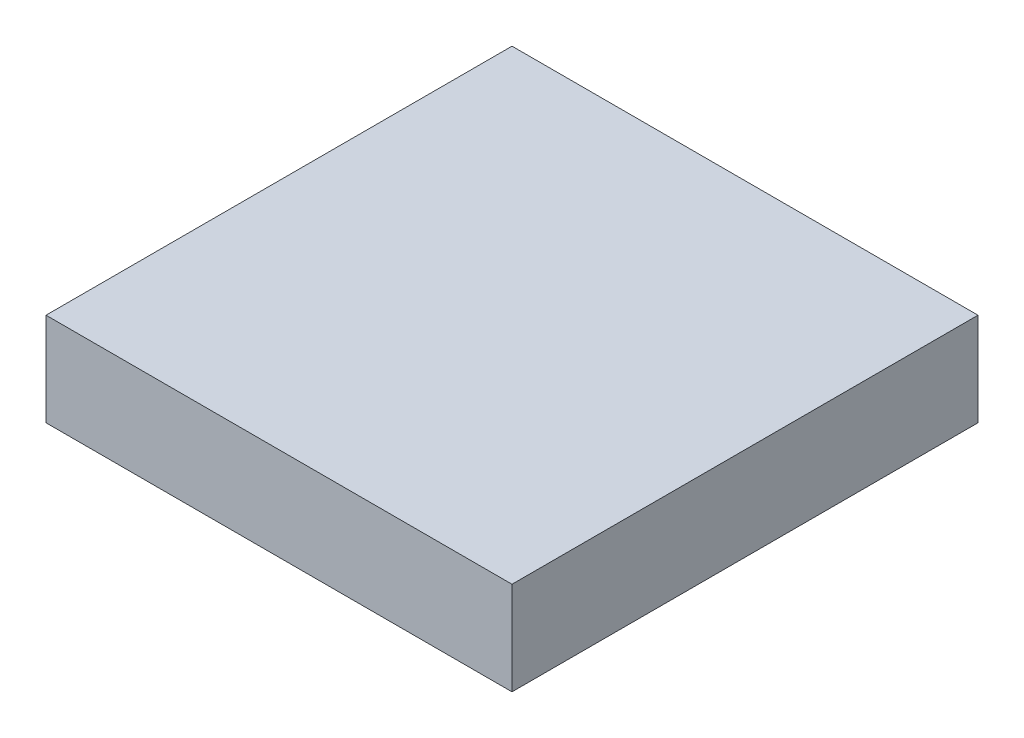
from build123d import *

# Parameters (mm, degrees)
SKETCH1_W           = 15
SKETCH1_H           = 15
BOSS_EXTRUDE1_DEPTH = 3
SKETCH2_R           = 6
SKETCH2_R_2         = 2.5
CUT_EXTRUDE1_DEPTH  = 2
SKETCH3_R           = 1.25
CUT_EXTRUDE2_DEPTH  = 2


with BuildPart() as part:
    # Sketch1 → Boss-Extrude1 (new body)
    with BuildSketch(Plane(origin=(0, 0, 0), x_dir=(1, 0, 0), z_dir=(0, 1, 0))):
        Rectangle(SKETCH1_W, SKETCH1_H)
    extrude(amount=BOSS_EXTRUDE1_DEPTH)

    # Sketch2 → Cut-Extrude1 (cut)
    with BuildSketch(Plane.XZ):
        Circle(SKETCH2_R)
        Circle(SKETCH2_R_2, mode=Mode.SUBTRACT)
    extrude(amount=-CUT_EXTRUDE1_DEPTH, mode=Mode.SUBTRACT)

    # Sketch3 → Cut-Extrude2 (cut)
    with BuildSketch(Plane.XZ):
        with Locations((-5.5, 5.5)):
            Circle(SKETCH3_R)
        with Locations((5.5, 5.5)):
            Circle(SKETCH3_R)
        with Locations((5.5, -5.5)):
            Circle(SKETCH3_R)
        with Locations((-5.5, -5.5)):
            Circle(SKETCH3_R)
    extrude(amount=-CUT_EXTRUDE2_DEPTH, mode=Mode.SUBTRACT)


solid = part.part
